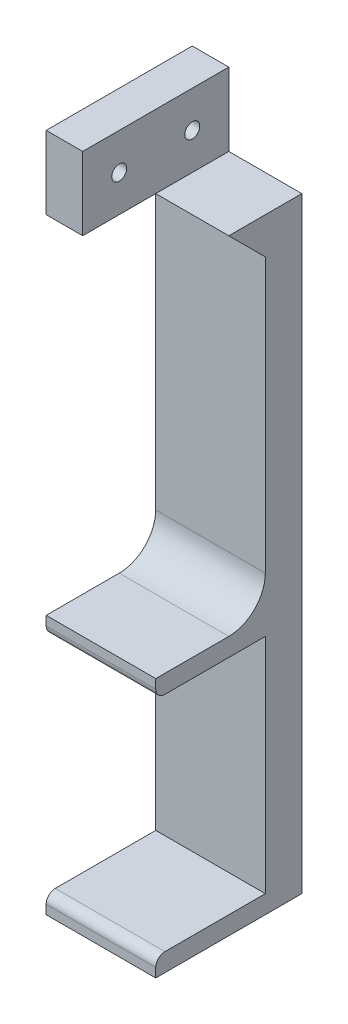
from build123d import *

# Parameters (mm, degrees)
SKETCH_1_W          = 30
SKETCH_1_H          = 186
EXTRUDE_1_DEPTH     = 10
SKETCH_2_W          = 30
SKETCH_2_H          = 5
SKETCH_2_H_2        = 20
EXTRUDE_2_DEPTH     = 30
FILLET_1_R          = 2.5
FILLET_4_R          = 10
CHAMFER_7_SIZE      = 10
SKETCH_9_W          = 40
SKETCH_9_H          = 20
CUT_EXTRUDE_5_DEPTH = 20
SKETCH_10_R         = 2.05
CUT_EXTRUDE_6_DEPTH = 10
SKETCH_11_R         = 3.75
CUT_EXTRUDE_7_DEPTH = 4


with BuildPart() as part:
    # 草圖1 → 填料-伸長1 (new body)
    with BuildSketch(Plane.XY):
        with Locations((3.2037008, 67.330357143)):
            Rectangle(SKETCH_1_W, SKETCH_1_H)
    extrude(amount=EXTRUDE_1_DEPTH)

    # 草圖2 → 填料-伸長2 (add)
    with BuildSketch(Plane.XY.offset(10)):
        with Locations((3.2037008, -23.169642857)):
            Rectangle(SKETCH_2_W, SKETCH_2_H)
        with Locations((3.2037008, 42.830357143)):
            Rectangle(SKETCH_2_W, SKETCH_2_H)
        with Locations((3.2037008, 150.330357143)):
            Rectangle(SKETCH_2_W, SKETCH_2_H_2)
    extrude(amount=EXTRUDE_2_DEPTH)

    # 圓角1
    fillet_1_edges = [part.edges().sort_by_distance(p)[0] for p in [
        (3.2037008, -20.669642857, 40),
        (3.2037008, 40.330357143, 40),
    ]]
    fillet(fillet_1_edges, radius=FILLET_1_R)

    # 圓角4
    fillet_4_edges = [part.edges().sort_by_distance(p)[0] for p in [
        (3.2037008, 45.330357143, 10),
    ]]
    fillet(fillet_4_edges, radius=FILLET_4_R)

    # 導角7
    chamfer_7_edges = [part.edges().sort_by_distance(p)[0] for p in [
        (3.2037008, 140.330357143, 10),
    ]]
    chamfer(chamfer_7_edges, length=CHAMFER_7_SIZE)

    # 草圖9 → 除料-伸長5 (cut)
    with BuildSketch(Plane(origin=(18.2037008, 0, 0), x_dir=(0, 0, -1), z_dir=(1, 0, 0))):
        with Locations((-20, 150.330357143)):
            Rectangle(SKETCH_9_W, SKETCH_9_H)
    extrude(amount=-CUT_EXTRUDE_5_DEPTH, mode=Mode.SUBTRACT)

    # 草圖10 → 除料-伸長6 (cut)
    with BuildSketch(Plane.ZY.offset(11.7962992)):
        with Locations((10, 150.330357143)):
            Circle(SKETCH_10_R)
        with Locations((30, 150.330357143)):
            Circle(SKETCH_10_R)
    extrude(amount=-CUT_EXTRUDE_6_DEPTH, mode=Mode.SUBTRACT)

    # 草圖11 → 除料-伸長7 (cut)
    with BuildSketch(Plane.ZY.offset(11.7962992)):
        with Locations((10, 150.330357143)):
            Circle(SKETCH_11_R)
        with Locations((30, 150.330357143)):
            Circle(SKETCH_11_R)
    extrude(amount=-CUT_EXTRUDE_7_DEPTH, mode=Mode.SUBTRACT)


solid = part.part
